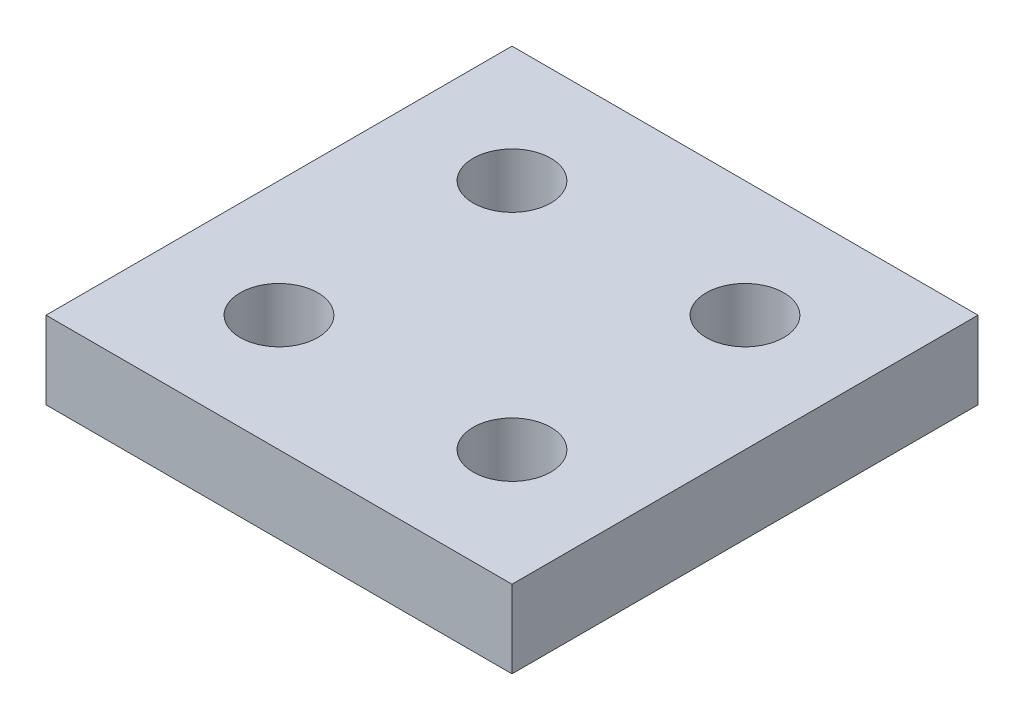
from build123d import *

# Parameters (mm, degrees)
SKETCH1_W            = 60
SKETCH1_H            = 60
BOSS_EXTRUDE1_DEPTH  = 10
SKETCH2_R            = 5
CUT_EXTRUDE1_DEPTH   = 11
LPATTERN1_COUNT      = 4
LPATTERN1_PITCH      = 30
LPATTERN1_COUNT_DIR2 = 4
LPATTERN1_PITCH_DIR2 = 30


with BuildPart() as part:
    # Sketch1 → Boss-Extrude1 (new body)
    with BuildSketch(Plane(origin=(0, 0, 0), x_dir=(1, 0, 0), z_dir=(0, 1, 0))):
        with Locations((30, 30)):
            Rectangle(SKETCH1_W, SKETCH1_H)
    extrude(amount=BOSS_EXTRUDE1_DEPTH)

    # Sketch2 → Cut-Extrude1 (cut, through all)
    with BuildSketch(Plane(origin=(0, 10, 0), x_dir=(1, 0, 0), z_dir=(0, 1, 0))):
        with Locations((15, 15)):
            Circle(SKETCH2_R)
    cut_extrude1 = extrude(amount=-CUT_EXTRUDE1_DEPTH, mode=Mode.SUBTRACT)

    # LPattern1: Cut-Extrude1 4 × 4
    with Locations(*[(i * LPATTERN1_PITCH, 0, -j * LPATTERN1_PITCH_DIR2) for i in range(LPATTERN1_COUNT) for j in range(LPATTERN1_COUNT_DIR2) if (i, j) != (0, 0)]):
        add(cut_extrude1, mode=Mode.SUBTRACT)


solid = part.part
